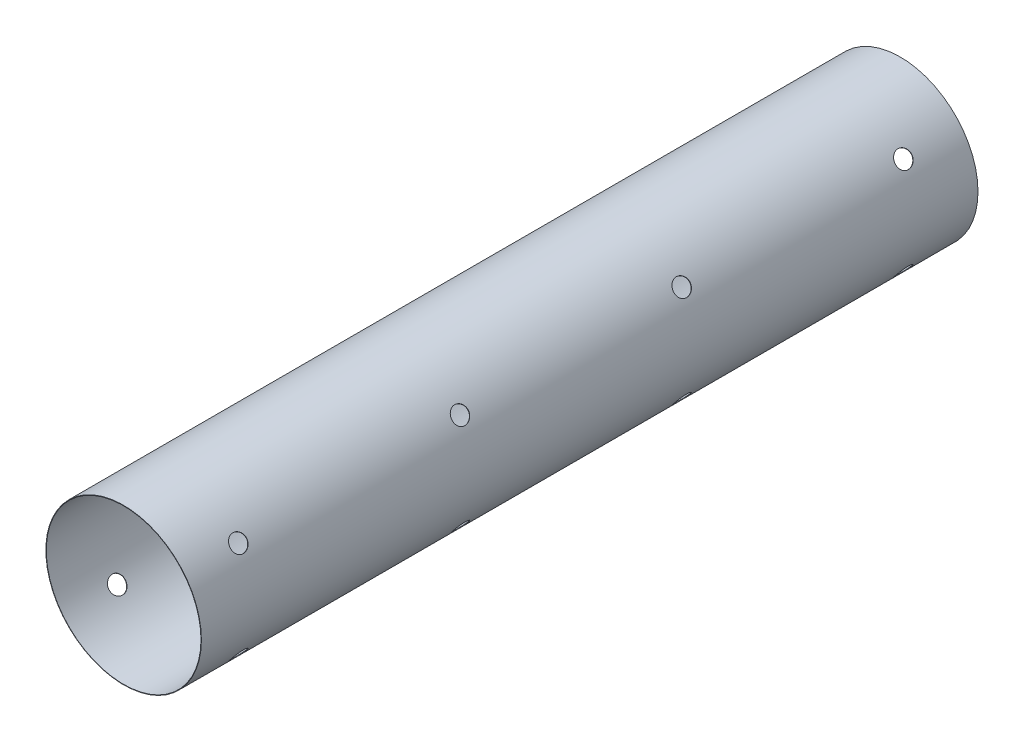
from build123d import *

# Parameters (mm, degrees)
SKETCH1_R                 = 216.125
SKETCH1_R_2               = 214.975
EXTRUDE1_DEPTH            = 1079
SKETCH2_R                 = 23
EXTRUDE2_DEPTH            = 304.725585803
EXTRUDE3_START            = -216.125
SKETCH3_R                 = 23
EXTRUDE3_DEPTH            = 2.383917
LPATTERN1_COUNT           = 4
LPATTERN1_PITCH           = 616
LPATTERN1_COPY_1_SKETCH_R = 23
LPATTERN1_COPY_1_DEPTH    = 304.725585803
LPATTERN1_COPY_2_SKETCH_R = 23
LPATTERN1_COPY_2_DEPTH    = 304.725585803
LPATTERN1_COPY_3_SKETCH_R = 23
LPATTERN1_COPY_3_DEPTH    = 304.725585803
LPATTERN1_START           = -216.125
LPATTERN1_COPY_4_SKETCH_R = 23
LPATTERN1_COPY_4_DEPTH    = 2.383917
LPATTERN1_COPY_5_SKETCH_R = 23
LPATTERN1_COPY_5_DEPTH    = 2.383917
LPATTERN1_COPY_6_SKETCH_R = 23
LPATTERN1_COPY_6_DEPTH    = 2.383917


with BuildPart() as part:
    # Sketch1 → Extrude1 (new body, symmetric)
    with BuildSketch(Plane.XY):
        Circle(SKETCH1_R)
        Circle(SKETCH1_R_2, mode=Mode.SUBTRACT)
    extrude(amount=EXTRUDE1_DEPTH, both=True)

    # Sketch2 → Extrude2 (cut, through all)
    with BuildSketch(Plane(origin=(0, 0, 0), x_dir=(0, 0, 1), z_dir=(-0.781821949, 0.623501756, 0))):
        with Locations(Location((-919, 0, 0), (0, 0, 90))):  # turned: the seam where the file's is
            Circle(SKETCH2_R)
    extrude2 = extrude(amount=EXTRUDE2_DEPTH, mode=Mode.SUBTRACT)

    # Sketch3 → Extrude3 (cut)
    with BuildSketch(Plane(origin=(0, 0, 0), x_dir=(0, 0, -1), z_dir=(0.781821949, 0.623501756, 0)).offset(EXTRUDE3_START)):
        with Locations(Location((919, 0, 0), (0, 0, 90))):  # turned: the seam where the file's is
            Circle(SKETCH3_R)
    extrude3 = extrude(amount=EXTRUDE3_DEPTH, mode=Mode.SUBTRACT)

    # Mirror1: Extrude2, Extrude3 across plane
    add(extrude2.mirror(Plane(origin=(0, 0, 0), x_dir=(0, 0, 1), z_dir=(1, 0, 0))), mode=Mode.SUBTRACT)
    add(extrude3.mirror(Plane(origin=(0, 0, 0), x_dir=(0, 0, 1), z_dir=(1, 0, 0))), mode=Mode.SUBTRACT)

    # LPattern1: Extrude2, Extrude3 ×4
    with Locations(*[(0, 0, i * LPATTERN1_PITCH) for i in range(1, LPATTERN1_COUNT)]):
        add(extrude2, mode=Mode.SUBTRACT)
        add(extrude3, mode=Mode.SUBTRACT)

    # LPattern1 copy 1 sketch → LPattern1 copy 1 (cut, through all)
    with BuildSketch(Plane(origin=(0, 0, 616), x_dir=(0, 0, 1), z_dir=(0.781821949, 0.623501756, 0))):
        with Locations((-919, 0)):
            Circle(LPATTERN1_COPY_1_SKETCH_R)
    extrude(amount=LPATTERN1_COPY_1_DEPTH, mode=Mode.SUBTRACT)

    # LPattern1 copy 2 sketch → LPattern1 copy 2 (cut, through all)
    with BuildSketch(Plane(origin=(0, 0, 1232), x_dir=(0, 0, 1), z_dir=(0.781821949, 0.623501756, 0))):
        with Locations((-919, 0)):
            Circle(LPATTERN1_COPY_2_SKETCH_R)
    extrude(amount=LPATTERN1_COPY_2_DEPTH, mode=Mode.SUBTRACT)

    # LPattern1 copy 3 sketch → LPattern1 copy 3 (cut, through all)
    with BuildSketch(Plane(origin=(0, 0, 1848), x_dir=(0, 0, 1), z_dir=(0.781821949, 0.623501756, 0))):
        with Locations((-919, 0)):
            Circle(LPATTERN1_COPY_3_SKETCH_R)
    extrude(amount=LPATTERN1_COPY_3_DEPTH, mode=Mode.SUBTRACT)

    # LPattern1 copy 4 sketch → LPattern1 copy 4 (cut)
    with BuildSketch(Plane(origin=(0, 0, 616), x_dir=(0, 0, -1), z_dir=(-0.781821949, 0.623501756, 0)).offset(LPATTERN1_START)):
        with Locations((919, 0)):
            Circle(LPATTERN1_COPY_4_SKETCH_R)
    extrude(amount=LPATTERN1_COPY_4_DEPTH, mode=Mode.SUBTRACT)

    # LPattern1 copy 5 sketch → LPattern1 copy 5 (cut)
    with BuildSketch(Plane(origin=(0, 0, 1232), x_dir=(0, 0, -1), z_dir=(-0.781821949, 0.623501756, 0)).offset(LPATTERN1_START)):
        with Locations((919, 0)):
            Circle(LPATTERN1_COPY_5_SKETCH_R)
    extrude(amount=LPATTERN1_COPY_5_DEPTH, mode=Mode.SUBTRACT)

    # LPattern1 copy 6 sketch → LPattern1 copy 6 (cut)
    with BuildSketch(Plane(origin=(0, 0, 1848), x_dir=(0, 0, -1), z_dir=(-0.781821949, 0.623501756, 0)).offset(LPATTERN1_START)):
        with Locations((919, 0)):
            Circle(LPATTERN1_COPY_6_SKETCH_R)
    extrude(amount=LPATTERN1_COPY_6_DEPTH, mode=Mode.SUBTRACT)


solid = part.part
